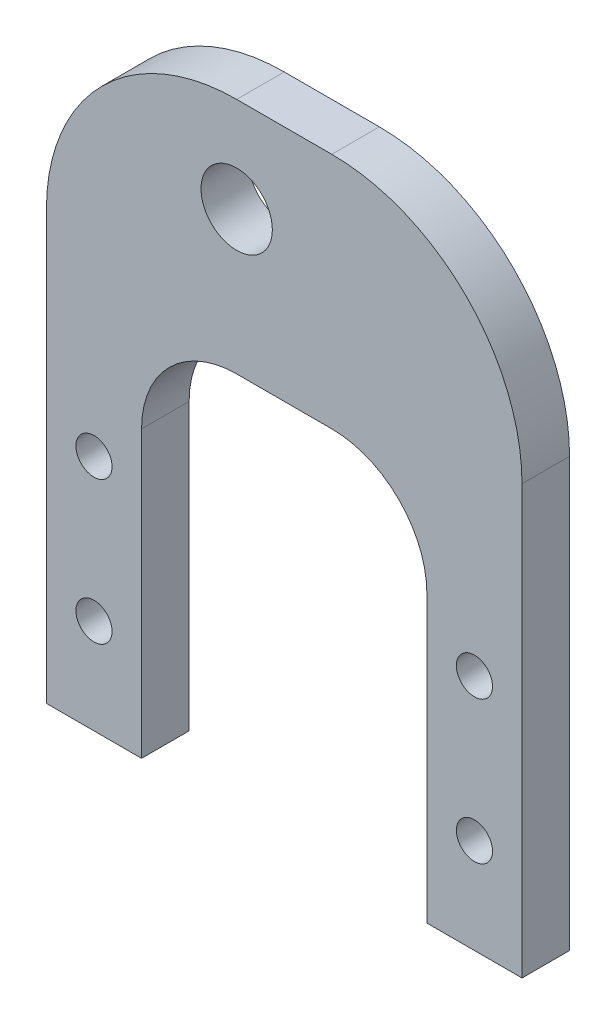
from build123d import *

# Parameters (mm, degrees)
BOSS_EXTRUDE1_DEPTH = 6.35
CUT_EXTRUDE1_REACH  = 8.35
SKETCH2_R           = 2.413
CUT_EXTRUDE2_REACH  = 8.35
SKETCH3_R           = 4.7625
FILLET1_R           = 12.7
FILLET2_R           = 25.4


with BuildPart() as part:
    # Sketch1 → Boss-Extrude1 (new body)
    with BuildSketch(Plane.XY):
        Polygon((0, 0), (12.7, 0), (12.7, 50.8), (50.8, 50.8), (50.8, 0), (63.5, 0), (63.5, 82.55), (0, 82.55), align=None)
    extrude(amount=BOSS_EXTRUDE1_DEPTH)

    # Sketch2 → Cut-Extrude1 (cut, up to next)
    with BuildSketch(Plane.XY.offset(6.35), mode=Mode.PRIVATE) as cut_extrude1_sk1:
        with Locations((6.35, 12.7)):
            Circle(SKETCH2_R)
    cut_extrude1_tool1 = extrude(cut_extrude1_sk1.sketch, amount=-CUT_EXTRUDE1_REACH, mode=Mode.PRIVATE) & part.part
    add(cut_extrude1_tool1.solids().sort_by_distance((6.35, 12.7, 6.35))[0], mode=Mode.SUBTRACT)
    # Sketch2 → Cut-Extrude1 (cut, up to next)
    with BuildSketch(Plane.XY.offset(6.35), mode=Mode.PRIVATE) as cut_extrude1_sk2:
        with Locations((6.35, 31.75)):
            Circle(SKETCH2_R)
    cut_extrude1_tool2 = extrude(cut_extrude1_sk2.sketch, amount=-CUT_EXTRUDE1_REACH, mode=Mode.PRIVATE) & part.part
    add(cut_extrude1_tool2.solids().sort_by_distance((6.35, 31.75, 6.35))[0], mode=Mode.SUBTRACT)
    # Sketch2 → Cut-Extrude1 (cut, up to next)
    with BuildSketch(Plane.XY.offset(6.35), mode=Mode.PRIVATE) as cut_extrude1_sk3:
        with Locations((57.15, 12.7)):
            Circle(SKETCH2_R)
    cut_extrude1_tool3 = extrude(cut_extrude1_sk3.sketch, amount=-CUT_EXTRUDE1_REACH, mode=Mode.PRIVATE) & part.part
    add(cut_extrude1_tool3.solids().sort_by_distance((57.15, 12.7, 6.35))[0], mode=Mode.SUBTRACT)
    # Sketch2 → Cut-Extrude1 (cut, up to next)
    with BuildSketch(Plane.XY.offset(6.35), mode=Mode.PRIVATE) as cut_extrude1_sk4:
        with Locations((57.15, 31.75)):
            Circle(SKETCH2_R)
    cut_extrude1_tool4 = extrude(cut_extrude1_sk4.sketch, amount=-CUT_EXTRUDE1_REACH, mode=Mode.PRIVATE) & part.part
    add(cut_extrude1_tool4.solids().sort_by_distance((57.15, 31.75, 6.35))[0], mode=Mode.SUBTRACT)

    # Sketch3 → Cut-Extrude2 (cut, up to next)
    with BuildSketch(Plane.XY.offset(6.35), mode=Mode.PRIVATE) as cut_extrude2_sk1:
        with Locations((25.4, 69.85)):
            Circle(SKETCH3_R)
    cut_extrude2_tool1 = extrude(cut_extrude2_sk1.sketch, amount=-CUT_EXTRUDE2_REACH, mode=Mode.PRIVATE) & part.part
    add(cut_extrude2_tool1.solids().sort_by_distance((25.4, 69.85, 6.35))[0], mode=Mode.SUBTRACT)

    # Fillet1
    fillet1_edges = [part.edges().sort_by_distance(p)[0] for p in [
        (50.8, 50.8, 3.175),
        (12.7, 50.8, 3.175),
    ]]
    fillet(fillet1_edges, radius=FILLET1_R)

    # Fillet2
    fillet2_edges = [part.edges().sort_by_distance(p)[0] for p in [
        (0, 82.55, 3.175),
        (63.5, 82.55, 3.175),
    ]]
    fillet(fillet2_edges, radius=FILLET2_R)


solid = part.part
